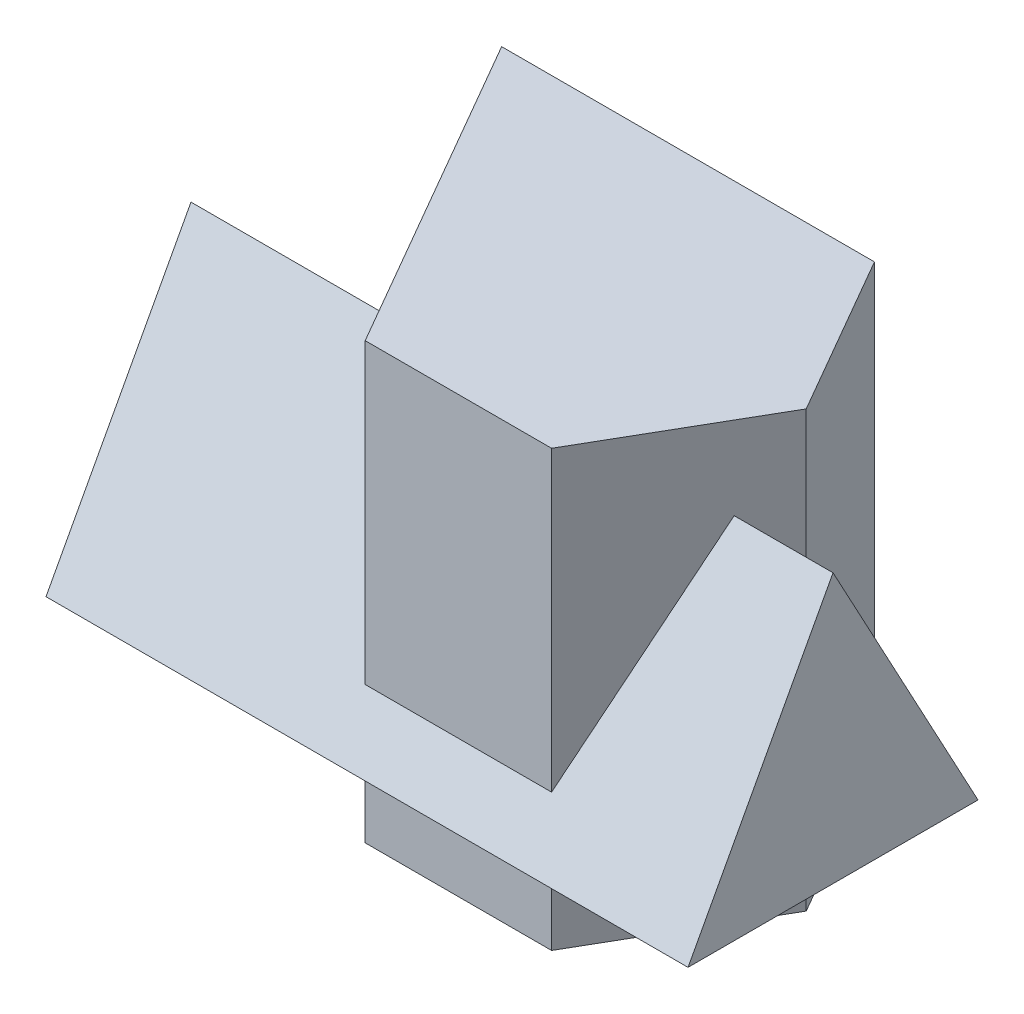
from build123d import *

# Parameters (mm, degrees)
EXTRUDE1_DEPTH = 105
EXTRUDE2_START = 62.5
EXTRUDE2_DEPTH = 155


with BuildPart() as part:
    # Sketch1 → Extrude1 (new body)
    with BuildSketch(Plane(origin=(0, 0, 0), x_dir=(1, 0, 0), z_dir=(0, 1, 0))):
        Polygon((45, 0), (22.5, 38.97114317), (-67.5, 38.97114317), (-22.5, -38.97114317), (22.5, -38.97114317), align=None)
    extrude(amount=EXTRUDE1_DEPTH)


with BuildPart() as body_2:
    # Sketch2 → Extrude2 (new body)
    with BuildSketch(Plane(origin=(0, 0, 0), x_dir=(0, 0, -1), z_dir=(1, 0, 0)).offset(EXTRUDE2_START)):
        Polygon((-46.02885683, 20), (23.97114317, 20), (-11.02885683, 85), align=None)
    extrude(amount=-EXTRUDE2_DEPTH)


solid = Compound([part.part, body_2.part])
